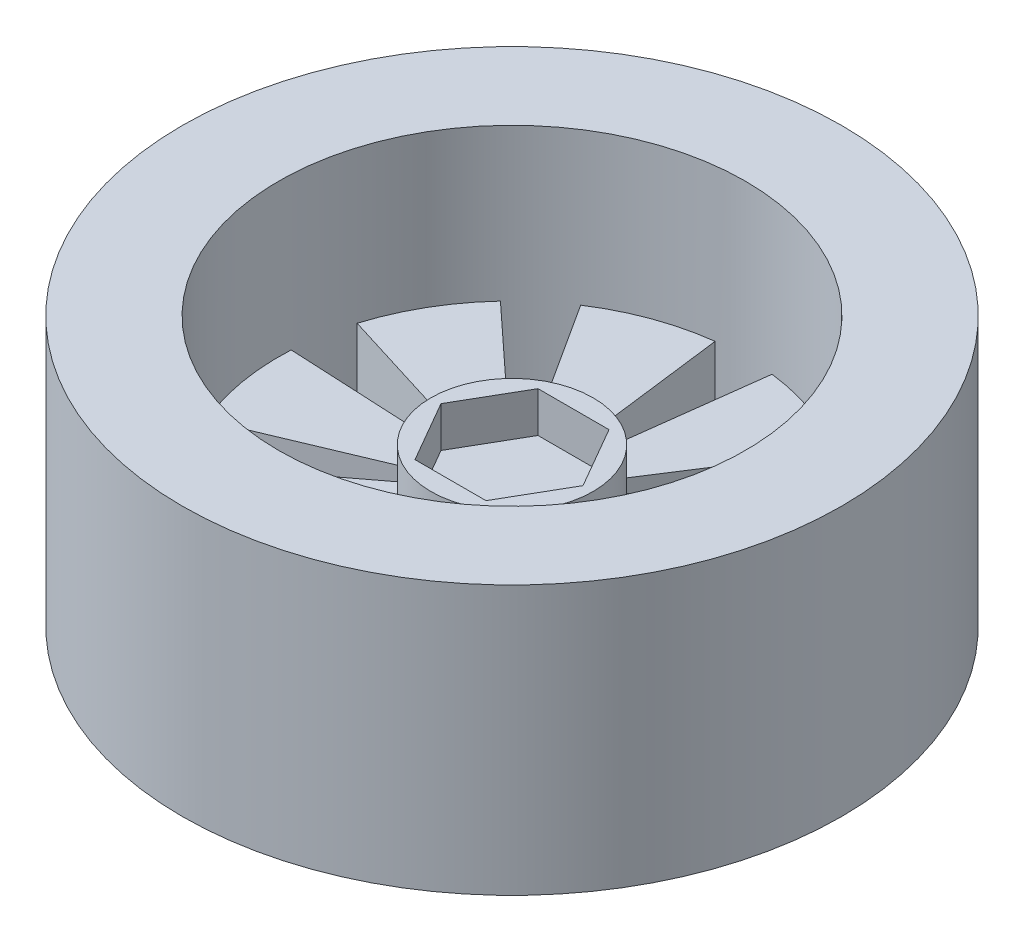
from build123d import *

# Parameters (mm, degrees)
SKETCH_1_W          = 32.5
SKETCH_1_H          = 26.5
SKETCH_2_R          = 23
CUT_EXTRUDE_1_DEPTH = 15
SKETCH_3_R          = 8
EXTRUDE_1_DEPTH     = 4
CUT_EXTRUDE_2_DEPTH = 12.5


with BuildPart() as part:
    # 草图1 → 旋转1 (revolve)
    with BuildSketch(Plane.XY):
        with Locations((16.25, 13.25)):
            Rectangle(SKETCH_1_W, SKETCH_1_H)
    revolve(axis=Axis((0, 54.381188119, 0), (0, -1, 0)))

    # 草图2 → 切除-拉伸1 (cut)
    with BuildSketch(Plane(origin=(0, 26.5, 0), x_dir=(1, 0, 0), z_dir=(0, 1, 0))):
        Circle(SKETCH_2_R)
    extrude(amount=-CUT_EXTRUDE_1_DEPTH, mode=Mode.SUBTRACT)

    # 草图3 → 凸台-拉伸1 (add)
    with BuildSketch(Plane(origin=(0, 11.5, 0), x_dir=(1, 0, 0), z_dir=(0, 1, 0))):
        Circle(SKETCH_3_R)
        Polygon((-3.5, 6.062177826), (3.5, 6.062177826), (7, 0), (3.5, -6.062177826), (-3.5, -6.062177826), (-7, 0), align=None, mode=Mode.SUBTRACT)
    extrude(amount=EXTRUDE_1_DEPTH)

    # 草图4 → 切除-拉伸2 (cut, through all)
    with BuildSketch(Plane(origin=(0, 11.5, 0), x_dir=(1, 0, 0), z_dir=(0, 1, 0))):
        with BuildLine():
            Line((-0.925251662, 7.9463142), (-2.807719573, 22.827980874))
            ThreePointArc((-2.807719573, 22.827980874), (0, 23), (2.807719573, 22.827980874))
            Line((2.807719573, 22.827980874), (0.925251662, 7.9463142))
            ThreePointArc((0.925251662, 7.9463142), (0, 8), (-0.925251662, 7.9463142))
        make_face()
        with BuildLine():
            Line((5.816576204, 5.492489532), (16.824381237, 15.682480544))
            ThreePointArc((16.824381237, 15.682480544), (14.784115023, 17.619022192), (12.522705284, 19.292015249))
            Line((12.522705284, 19.292015249), (4.399008416, 6.68197014))
            ThreePointArc((4.399008416, 6.68197014), (5.142300877, 6.128355545), (5.816576204, 5.492489532))
        make_face()
        with BuildLine():
            Line((7.986260097, 0.46866797), (22.968727938, 1.198973275))
            ThreePointArc((22.968727938, 1.198973275), (22.650578319, 3.993908086), (21.993617163, 6.729101282))
            Line((21.993617163, 6.729101282), (7.664923567, 2.29105799))
            ThreePointArc((7.664923567, 2.29105799), (7.878462024, 1.389185421), (7.986260097, 0.46866797))
        make_face()
        with BuildLine():
            Line((6.419084133, -4.774448544), (18.365751568, -13.845546914))
            ThreePointArc((18.365751568, -13.845546914), (19.918584287, -11.5), (21.173471141, -8.98243396))
            Line((21.173471141, -8.98243396), (7.344335794, -3.171865656))
            ThreePointArc((7.344335794, -3.171865656), (6.92820323, -4), (6.419084133, -4.774448544))
        make_face()
        with BuildLine():
            Line((1.848347363, -7.783547522), (5.169235927, -22.411581826))
            ThreePointArc((5.169235927, -22.411581826), (7.866463296, -21.612930278), (10.446022654, -20.490988524))
            Line((10.446022654, -20.490988524), (3.58725168, -7.15063811))
            ThreePointArc((3.58725168, -7.15063811), (2.736161147, -7.517540966), (1.848347363, -7.783547522))
        make_face()
        with BuildLine():
            Line((-3.58725168, -7.15063811), (-10.446022654, -20.490988524))
            ThreePointArc((-10.446022654, -20.490988524), (-7.866463296, -21.612930278), (-5.169235927, -22.411581826))
            Line((-5.169235927, -22.411581826), (-1.848347363, -7.783547522))
            ThreePointArc((-1.848347363, -7.783547522), (-2.736161147, -7.517540966), (-3.58725168, -7.15063811))
        make_face()
        with BuildLine():
            Line((-7.344335794, -3.171865656), (-21.173471141, -8.98243396))
            ThreePointArc((-21.173471141, -8.98243396), (-19.918584287, -11.5), (-18.365751568, -13.845546914))
            Line((-18.365751568, -13.845546914), (-6.419084133, -4.774448544))
            ThreePointArc((-6.419084133, -4.774448544), (-6.92820323, -4), (-7.344335794, -3.171865656))
        make_face()
        with BuildLine():
            Line((-7.664923567, 2.29105799), (-21.993617163, 6.729101282))
            ThreePointArc((-21.993617163, 6.729101282), (-22.650578319, 3.993908086), (-22.968727938, 1.198973275))
            Line((-22.968727938, 1.198973275), (-7.986260097, 0.46866797))
            ThreePointArc((-7.986260097, 0.46866797), (-7.878462024, 1.389185421), (-7.664923567, 2.29105799))
        make_face()
        with BuildLine():
            Line((-4.399008416, 6.68197014), (-12.522705284, 19.292015249))
            ThreePointArc((-12.522705284, 19.292015249), (-14.784115023, 17.619022192), (-16.824381237, 15.682480544))
            Line((-16.824381237, 15.682480544), (-5.816576204, 5.492489532))
            ThreePointArc((-5.816576204, 5.492489532), (-5.142300877, 6.128355545), (-4.399008416, 6.68197014))
        make_face()
    extrude(amount=-CUT_EXTRUDE_2_DEPTH, mode=Mode.SUBTRACT)


solid = part.part
